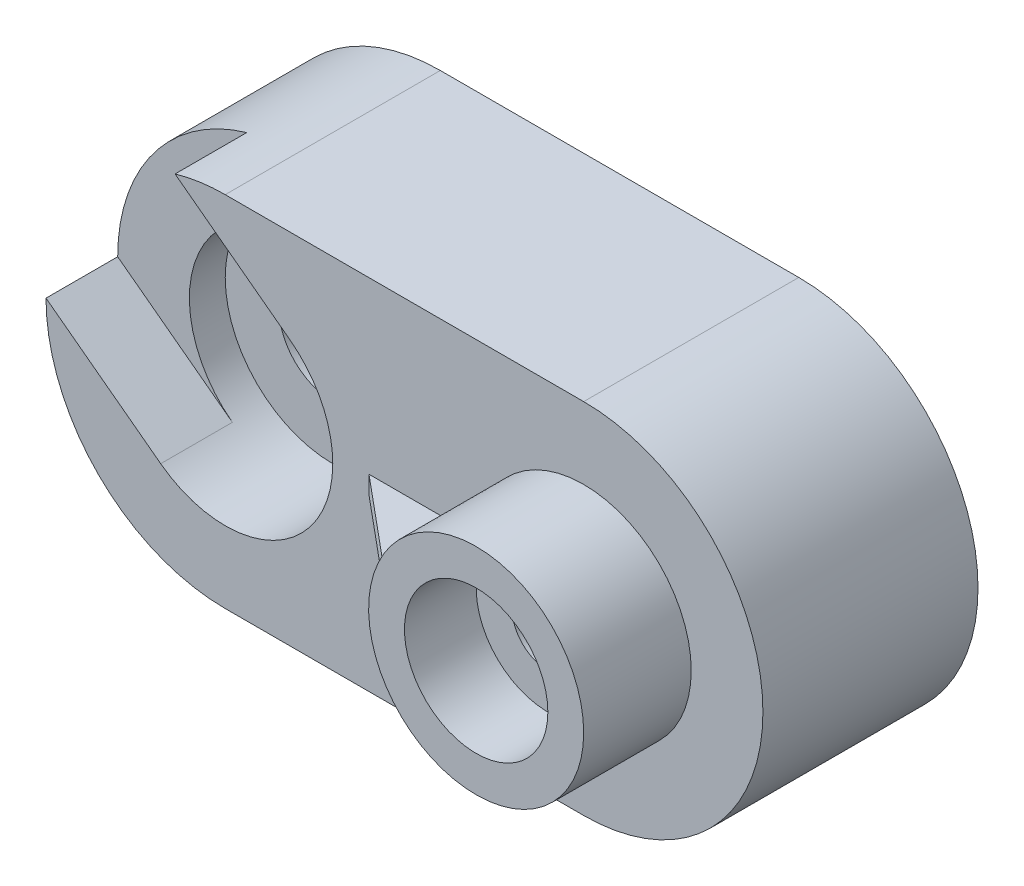
from build123d import *

# Parameters (mm, degrees)
BOSS_EXTRUDE1_DEPTH = 60
CUT_EXTRUDE1_DEPTH  = 10
SKETCH3_R           = 30
BOSS_EXTRUDE2_DEPTH = 30
SKETCH4_R           = 20
CUT_EXTRUDE3_DEPTH  = 20
SKETCH5_R           = 10
CUT_EXTRUDE4_DEPTH  = 129
SKETCH7_W           = 30
SKETCH7_H           = 5
BOSS_EXTRUDE3_DEPTH = 25
CUT_EXTRUDE5_DEPTH  = 20
SKETCH9_R           = 30
CUT_EXTRUDE6_DEPTH  = 10
SKETCH10_R          = 15
CUT_EXTRUDE7_DEPTH  = 155
CUT_EXTRUDE8_DEPTH  = 10


with BuildPart() as part:
    # Sketch1 → Boss-Extrude1 (new body)
    with BuildSketch(Plane.XY):
        with BuildLine():
            Line((0, 50), (100, 50))
            ThreePointArc((100, 50), (150, 0), (100, -50))
            Line((100, -50), (0, -50))
            ThreePointArc((0, -50), (-50, 0), (0, 50))
        make_face()
    extrude(amount=BOSS_EXTRUDE1_DEPTH)

    # Sketch2 → Cut-Extrude1 (cut)
    with BuildSketch(Plane(origin=(0, 0, 0), x_dir=(-1, 0, 0), z_dir=(0, 0, -1))):
        with BuildLine():
            Line((0, -30), (-100, -30))
            ThreePointArc((-100, -30), (-130, 0), (-100, 30))
            Line((-100, 30), (0, 30))
            ThreePointArc((0, 30), (30, 0), (0, -30))
        make_face()
    extrude(amount=-CUT_EXTRUDE1_DEPTH, mode=Mode.SUBTRACT)

    # Sketch3 → Boss-Extrude2 (add)
    with BuildSketch(Plane.XY.offset(60)):
        with Locations((100, 0)):
            Circle(SKETCH3_R)
    extrude(amount=BOSS_EXTRUDE2_DEPTH)

    # Sketch4 → Cut-Extrude3 (cut)
    with BuildSketch(Plane.XY.offset(90)):
        with Locations((100, 0)):
            Circle(SKETCH4_R)
    extrude(amount=-CUT_EXTRUDE3_DEPTH, mode=Mode.SUBTRACT)

    # Sketch5 → Cut-Extrude4 (cut)
    with BuildSketch(Plane.XY.offset(70)):
        with Locations((100, 0)):
            Circle(SKETCH5_R)
    extrude(amount=-CUT_EXTRUDE4_DEPTH, mode=Mode.SUBTRACT)

    # Sketch7 → Boss-Extrude3 (add)
    with BuildSketch(Plane.XY.offset(60)):
        with Locations((55.104348142, 0)):
            Rectangle(SKETCH7_W, SKETCH7_H)
    extrude(amount=BOSS_EXTRUDE3_DEPTH)

    # Sketch8 → Cut-Extrude5 (cut)
    with BuildSketch(Plane.XY.offset(60)):
        with BuildLine():
            ThreePointArc((-14, 48), (-40, 30), (-50, 0))
            Line((-50, 0), (-18, -24))
            ThreePointArc((-18, -24), (24, -18), (18, 24))
            Line((18, 24), (-14, 48))
        make_face()
    extrude(amount=-CUT_EXTRUDE5_DEPTH, mode=Mode.SUBTRACT)

    # Sketch9 → Cut-Extrude6 (cut)
    with BuildSketch(Plane.XY.offset(40)):
        Circle(SKETCH9_R)
    extrude(amount=-CUT_EXTRUDE6_DEPTH, mode=Mode.SUBTRACT)

    # Sketch10 → Cut-Extrude7 (cut)
    with BuildSketch(Plane.XY.offset(30)):
        Circle(SKETCH10_R)
    extrude(amount=-CUT_EXTRUDE7_DEPTH, mode=Mode.SUBTRACT)

    # Sketch11 → Cut-Extrude8 (cut)
    with BuildSketch(Plane.XZ.offset(2.5)):
        Polygon((40.104348142, 60), (70.104348142, 85), (40.104348142, 85), align=None)
    extrude(amount=-CUT_EXTRUDE8_DEPTH, mode=Mode.SUBTRACT)


solid = part.part
